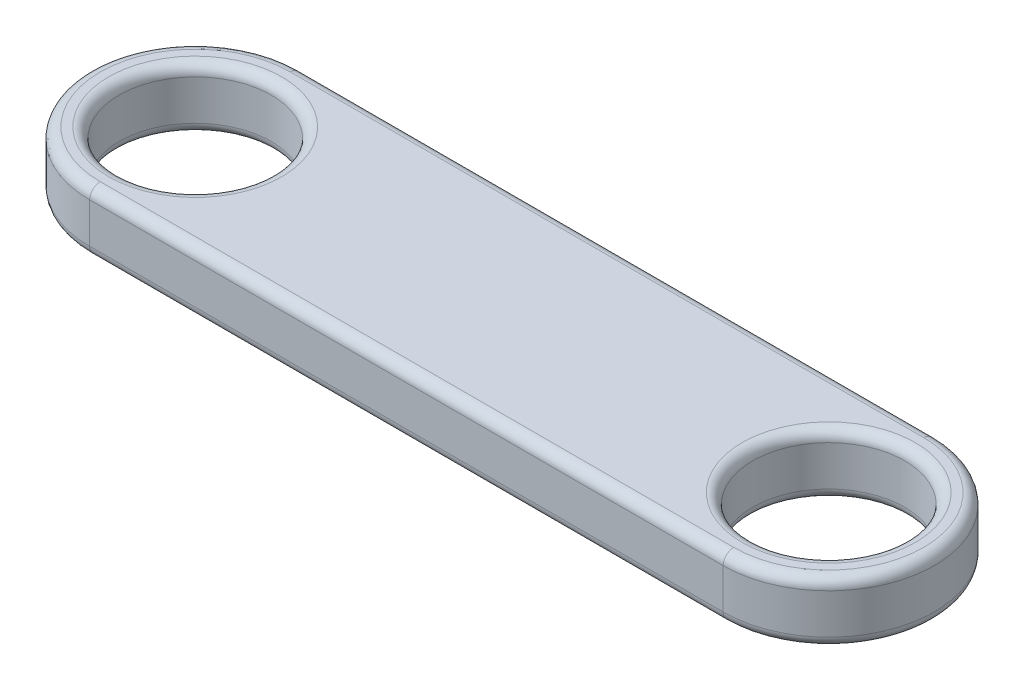
from build123d import *

# Parameters (mm, degrees)
SKETCH1_R           = 3.6
BOSS_EXTRUDE1_DEPTH = 2.9
FILLET1_R           = 0.5


with BuildPart() as part:
    # Sketch1 → Boss-Extrude1 (new body)
    with BuildSketch(Plane(origin=(0, 0, 0), x_dir=(1, 0, 0), z_dir=(0, 1, 0))):
        with BuildLine():
            Line((0, 5), (30, 5))
            ThreePointArc((30, 5), (35, 0), (30, -5))
            Line((30, -5), (0, -5))
            ThreePointArc((0, -5), (-5, 0), (0, 5))
        make_face()
        Circle(SKETCH1_R, mode=Mode.SUBTRACT)
        with Locations((30, 0)):
            Circle(SKETCH1_R, mode=Mode.SUBTRACT)
    extrude(amount=BOSS_EXTRUDE1_DEPTH)

    # Fillet1
    fillet1_edges = [part.edges().sort_by_distance(p)[0] for p in [
        (35, 2.9, 0),
        (-3.6, 0, 0),
        (-3.6, 2.9, 0),
        (15, 2.9, -5),
        (26.4, 0, 0),
        (26.4, 2.9, 0),
        (-5, 2.9, 0),
        (15, 0, -5),
        (35, 0, 0),
        (15, 0, 5),
        (-5, 0, 0),
        (15, 2.9, 5),
    ]]
    fillet(fillet1_edges, radius=FILLET1_R)


solid = part.part
